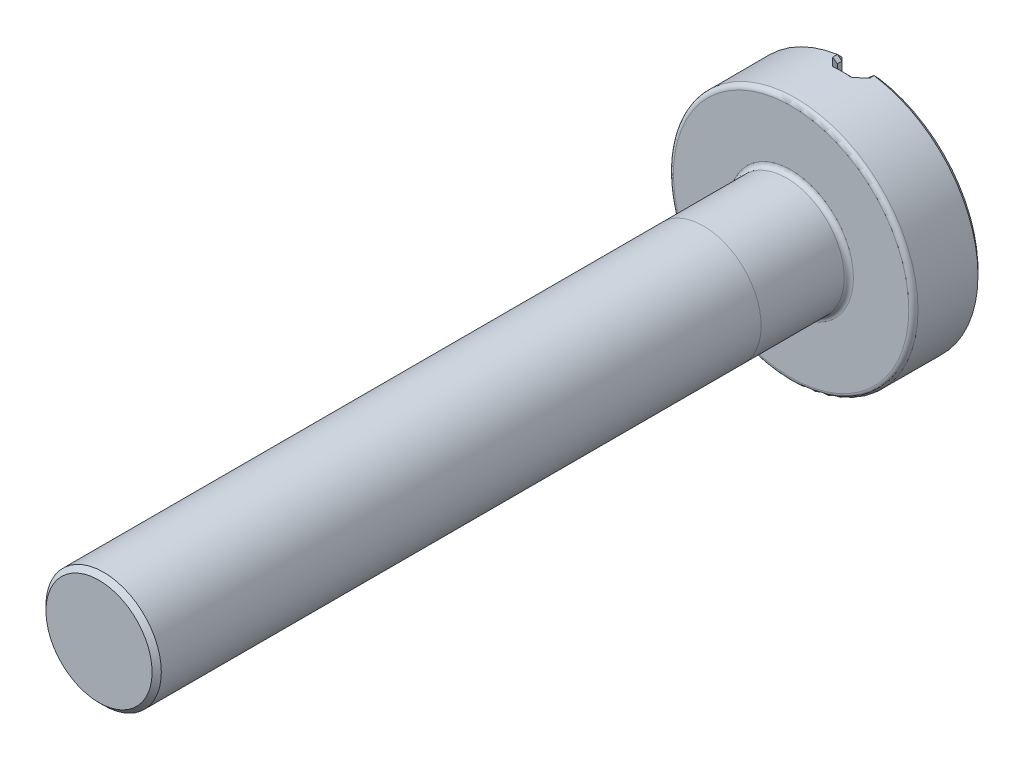
from build123d import *
from OCP.BRepFilletAPI import BRepFilletAPI_MakeChamfer

# Parameters (mm, degrees)
SKETCH1_R           = 0.625
BOSS_EXTRUDE1_DEPTH = 7.5
SKETCH2_R           = 1.325
BOSS_EXTRUDE2_DEPTH = 0.75
SKETCH3_W           = 0.3
SKETCH3_H           = 7.682003158
CUT_EXTRUDE1_DEPTH  = 0.15
CHAMFER1_SIZE       = 0.05
CHAMFER1_SIZE2      = 0.045176141
FILLET1_R           = 0.05
CHAMFER2_SIZE       = 0.05


with BuildPart() as part:
    # Sketch1 → Boss-Extrude1 (new body)
    with BuildSketch(Plane.XY):
        Circle(SKETCH1_R)
    extrude(amount=BOSS_EXTRUDE1_DEPTH)

    # Sketch2 → Boss-Extrude2 (add)
    with BuildSketch(Plane.XY):
        Circle(SKETCH2_R)
    extrude(amount=-BOSS_EXTRUDE2_DEPTH)

    # Sketch3 → Cut-Extrude1 (cut)
    with BuildSketch(Plane(origin=(0, 0, -0.75), x_dir=(-1, 0, 0), z_dir=(0, 0, -1))):
        Rectangle(SKETCH3_W, SKETCH3_H)
    extrude(amount=-CUT_EXTRUDE1_DEPTH, mode=Mode.SUBTRACT)

    # Chamfer1: one chamfer whose edges measure the first distance from different faces: ONE call of the kernel's chamfer builder (chamfer() names one face for all edges)
    chamfer1_edges_1 = [part.edges().sort_by_distance(p)[0] for p in [
        (-1.325, 0, -0.75),
        (0.988527946, 0.882291052, -0.75),
        (-0.15, 0, -0.75),
        (0.15, 0, -0.75),
        (0, 1.325, -0.6),
        (0, -1.325, -0.6),
        (0.15, 0, -0.6),
        (-0.15, 0, -0.6),
    ]]
    chamfer1_edges_2 = [part.edges().sort_by_distance(p)[0] for p in [
        (0.15, 1.316482055, -0.675),
        (0.15, -1.316482055, -0.675),
        (-0.15, -1.316482055, -0.675),
        (-0.15, 1.316482055, -0.675),
    ]]
    chamfer1_side_2 = [part.faces().sort_by_distance(p)[0] for p in [
        (-1.325, 0, -0.375),
    ]]
    chamfer1 = BRepFilletAPI_MakeChamfer(part.part.solid().wrapped)
    for e in chamfer1_edges_1:
        chamfer1.Add(CHAMFER1_SIZE, e.wrapped)
    for e in chamfer1_edges_2:
        chamfer1.Add(CHAMFER1_SIZE, CHAMFER1_SIZE2, e.wrapped, chamfer1_side_2[0].wrapped)  # the first distance lies on this face
    add(Compound.cast(chamfer1.Shape()), mode=Mode.REPLACE)

    # Fillet1
    fillet1_edges = [part.edges().sort_by_distance(p)[0] for p in [
        (-0.625, 0, 0),
        (-1.325, 0, 0),
    ]]
    fillet(fillet1_edges, radius=FILLET1_R)

    # Chamfer2
    chamfer2_edges = [part.edges().sort_by_distance(p)[0] for p in [
        (-0.625, 0, 7.5),
    ]]
    chamfer(chamfer2_edges, length=CHAMFER2_SIZE)


solid = part.part
